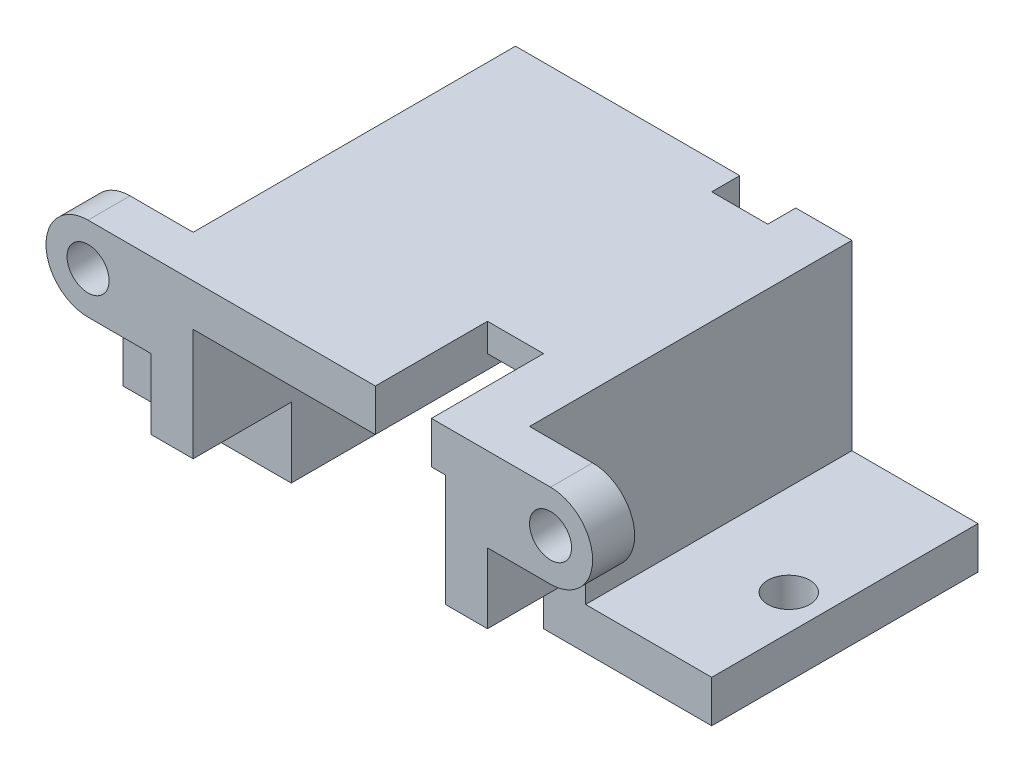
from build123d import *

# Parameters (mm, degrees)
EXTRU_MINCE1_DEPTH      = 13
EXTRUSION1_DEPTH        = 3
ESQUISSE3_R             = 1.5
ENL_V_MAT_EXTRU_1_DEPTH = 3
ENL_V_MAT_EXTRU_2_REACH = 18
ESQUISSE4_W             = 4
ESQUISSE4_H             = 8
ESQUISSE4_H_2           = 2
ESQUISSE6_W             = 7
ESQUISSE6_H             = 5
ENL_V_MAT_EXTRU_4_DEPTH = 42
ESQUISSE7_R             = 1.5
ENL_V_MAT_EXTRU_5_DEPTH = 3
ESQUISSE8_W             = 4
ESQUISSE8_H             = 16
ENL_V_MAT_EXTRU_6_DEPTH = 1


with BuildPart() as part:
    # Esquisse1 → Extru.-Mince1 (new body, symmetric)
    with BuildSketch(Plane.XY):
        Polygon((-21, 0), (-9, 0), (-9, 13), (9, 13), (9, 0), (21, 0), (21, 3), (12, 3), (12, 16), (-12, 16), (-12, 3), (-21, 3), align=None)
    extrude(amount=EXTRU_MINCE1_DEPTH, both=True)

    # Esquisse2 → Extrusion1 (add)
    with BuildSketch(Plane.XY.offset(13)):
        with BuildLine():
            Line((-12, 16), (-16.5, 16))
            ThreePointArc((-16.5, 16), (-19.5, 13), (-16.5, 10))
            Line((-16.5, 10), (-12, 10))
            Line((-12, 10), (-12, 16))
        make_face()
    extrusion1 = extrude(amount=-EXTRUSION1_DEPTH)

    # Esquisse3 → Enlèv. mat.-Extru.1 (cut)
    with BuildSketch(Plane.XY.offset(13)):
        with Locations((-16.5, 13)):
            Circle(ESQUISSE3_R)
    enl_v_mat_extru_1 = extrude(amount=-ENL_V_MAT_EXTRU_1_DEPTH, mode=Mode.SUBTRACT)

    # Symétrie1: Extrusion1, Enlèv. mat.-Extru.1 across plane
    add(extrusion1.mirror(Plane(origin=(0, 0, 0), x_dir=(0, 0, 1), z_dir=(1, 0, 0))))
    add(enl_v_mat_extru_1.mirror(Plane(origin=(0, 0, 0), x_dir=(0, 0, 1), z_dir=(1, 0, 0))), mode=Mode.SUBTRACT)

    # Esquisse4 → Enlèv. mat.-Extru.2 (cut, up to next)
    with BuildSketch(Plane(origin=(0, 16, 0), x_dir=(1, 0, 0), z_dir=(0, 1, 0)), mode=Mode.PRIVATE) as enl_v_mat_extru_2_sk1:
        with Locations((6, -9)):
            Rectangle(ESQUISSE4_W, ESQUISSE4_H)
    enl_v_mat_extru_2_tool1 = extrude(enl_v_mat_extru_2_sk1.sketch, amount=-ENL_V_MAT_EXTRU_2_REACH, mode=Mode.PRIVATE) & part.part
    add(enl_v_mat_extru_2_tool1.solids().sort_by_distance((6, 16, 9))[0], mode=Mode.SUBTRACT)
    # Esquisse4 → Enlèv. mat.-Extru.2 (cut, up to next)
    with BuildSketch(Plane(origin=(0, 16, 0), x_dir=(1, 0, 0), z_dir=(0, 1, 0)), mode=Mode.PRIVATE) as enl_v_mat_extru_2_sk2:
        with Locations((6, 12)):
            Rectangle(ESQUISSE4_W, ESQUISSE4_H_2)
    enl_v_mat_extru_2_tool2 = extrude(enl_v_mat_extru_2_sk2.sketch, amount=-ENL_V_MAT_EXTRU_2_REACH, mode=Mode.PRIVATE) & part.part
    add(enl_v_mat_extru_2_tool2.solids().sort_by_distance((6, 16, -12))[0], mode=Mode.SUBTRACT)

    # Esquisse6 → Enlèv. mat.-Extru.4 (cut)
    with BuildSketch(Plane(origin=(21, 0, 0), x_dir=(0, 0, -1), z_dir=(1, 0, 0))):
        with Locations((-9.5, 2.5)):
            Rectangle(ESQUISSE6_W, ESQUISSE6_H)
    extrude(amount=-ENL_V_MAT_EXTRU_4_DEPTH, mode=Mode.SUBTRACT)

    # Esquisse7 → Enlèv. mat.-Extru.5 (cut)
    with BuildSketch(Plane(origin=(0, 3, 0), x_dir=(1, 0, 0), z_dir=(0, 1, 0))):
        with Locations((18.5, 2)):
            Circle(ESQUISSE7_R)
    enl_v_mat_extru_5 = extrude(amount=-ENL_V_MAT_EXTRU_5_DEPTH, mode=Mode.SUBTRACT)

    # Symétrie2: Enlèv. mat.-Extru.5 across plane
    add(enl_v_mat_extru_5.mirror(Plane(origin=(0, 0, 0), x_dir=(0, 0, 1), z_dir=(1, 0, 0))), mode=Mode.SUBTRACT)

    # Esquisse8 → Enlèv. mat.-Extru.6 (cut)
    with BuildSketch(Plane.XZ.offset(-13)):
        with Locations((6, -3)):
            Rectangle(ESQUISSE8_W, ESQUISSE8_H)
    extrude(amount=-ENL_V_MAT_EXTRU_6_DEPTH, mode=Mode.SUBTRACT)


solid = part.part
